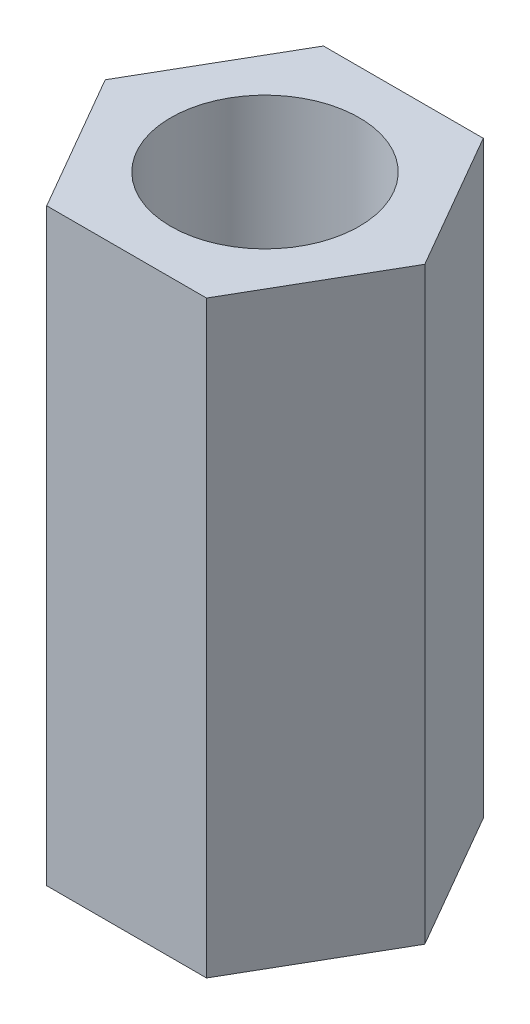
from build123d import *

# Parameters (mm, degrees)
EXTRUDE_1_DEPTH     = 10
SKETCH_2_R          = 1.6
CUT_EXTRUDE_1_DEPTH = 11


with BuildPart() as part:
    # 草图1 → 凸台-拉伸1 (new body)
    with BuildSketch(Plane(origin=(0, 0, 0), x_dir=(1, 0, 0), z_dir=(0, 1, 0))):
        Polygon((2.713546265, 0), (1.356773133, 2.35), (-1.356773133, 2.35), (-2.713546265, 0), (-1.356773133, -2.35), (1.356773133, -2.35), align=None)
    extrude(amount=EXTRUDE_1_DEPTH)

    # 草图2 → 切除-拉伸1 (cut, through all)
    with BuildSketch(Plane(origin=(0, 10, 0), x_dir=(1, 0, 0), z_dir=(0, 1, 0))):
        Circle(SKETCH_2_R)
    extrude(amount=-CUT_EXTRUDE_1_DEPTH, mode=Mode.SUBTRACT)


solid = part.part
